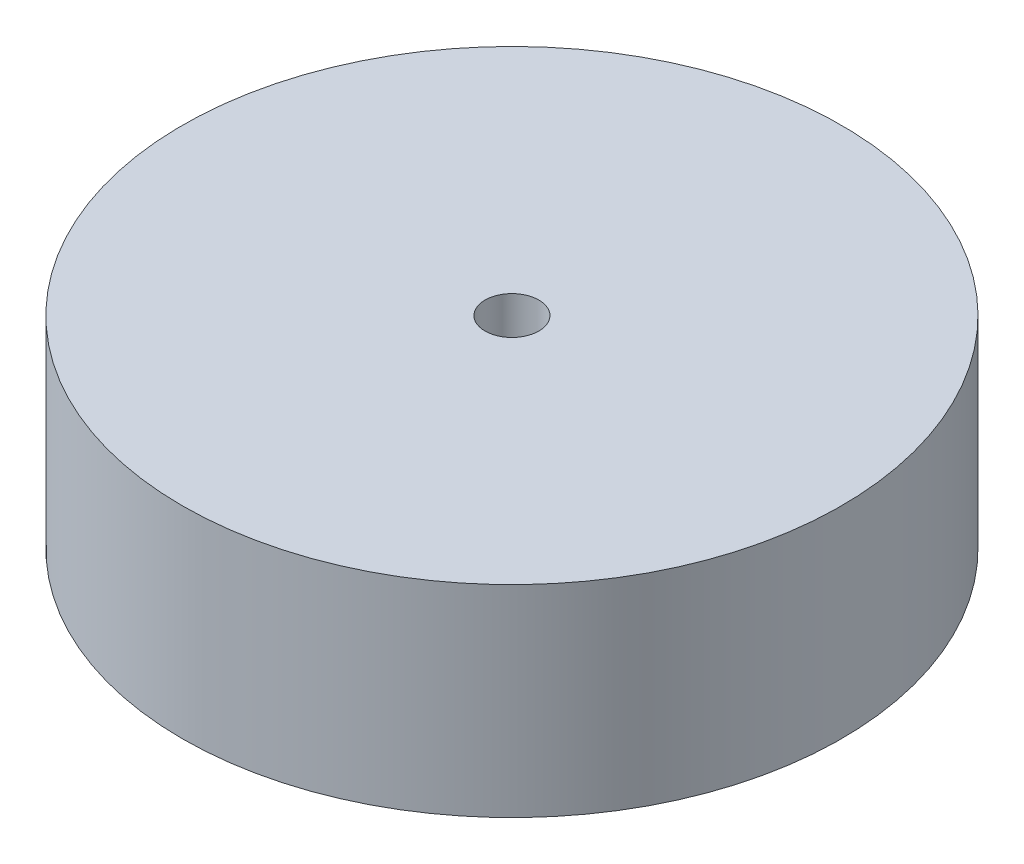
from build123d import *

# Parameters (mm, degrees)
SKETCH1_R               = 24.5
BOSS_EXTRUDE1_DEPTH     = 15
SKETCH2_R               = 2
CUT_EXTRUDE1_DEPTH      = 16
CUT_EXTRUDE1_DEPTH_BACK = 1


with BuildPart() as part:
    # Sketch1 → Boss-Extrude1 (new body)
    with BuildSketch(Plane(origin=(0, 0, 0), x_dir=(1, 0, 0), z_dir=(0, 1, 0))):
        Circle(SKETCH1_R)
    extrude(amount=BOSS_EXTRUDE1_DEPTH)

    # Sketch2 → Cut-Extrude1 (cut, two sides)
    with BuildSketch(Plane(origin=(0, 0, 0), x_dir=(1, 0, 0), z_dir=(0, 1, 0))) as cut_extrude1_sk:
        Circle(SKETCH2_R)
    extrude(amount=CUT_EXTRUDE1_DEPTH, mode=Mode.SUBTRACT)
    extrude(cut_extrude1_sk.sketch, amount=-CUT_EXTRUDE1_DEPTH_BACK, mode=Mode.SUBTRACT)


solid = part.part
